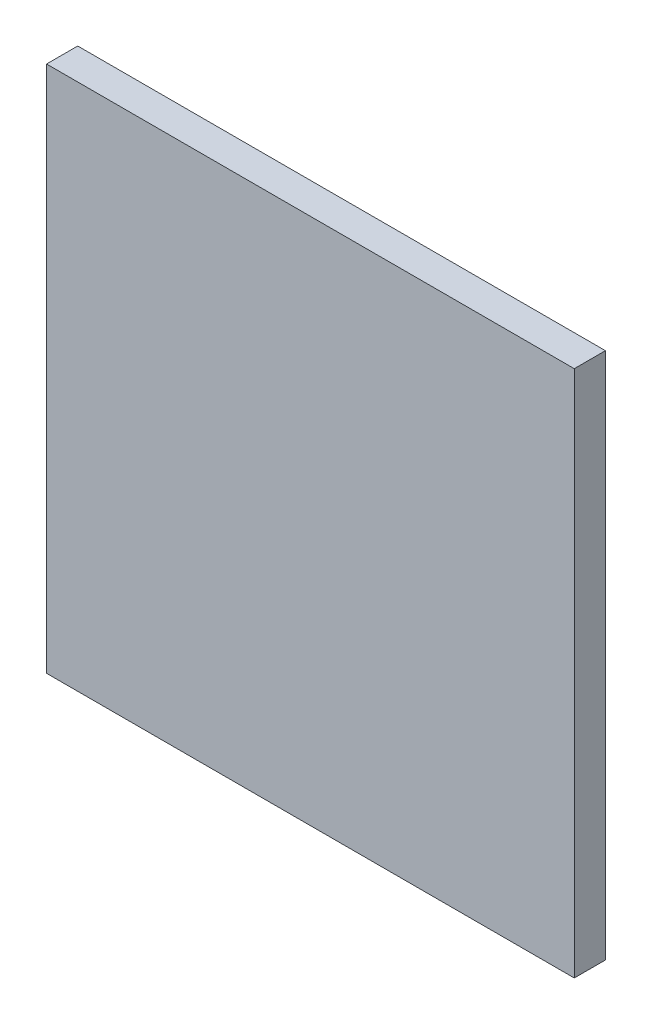
from build123d import *

# Parameters (mm, degrees)
SKETCH1_W           = 101.6
SKETCH1_H           = 101.6
BOSS_EXTRUDE2_DEPTH = 6


with BuildPart() as part:
    # Sketch1 → Boss-Extrude2 (new body)
    with BuildSketch(Plane.XY):
        Rectangle(SKETCH1_W, SKETCH1_H)
    extrude(amount=BOSS_EXTRUDE2_DEPTH)


solid = part.part
